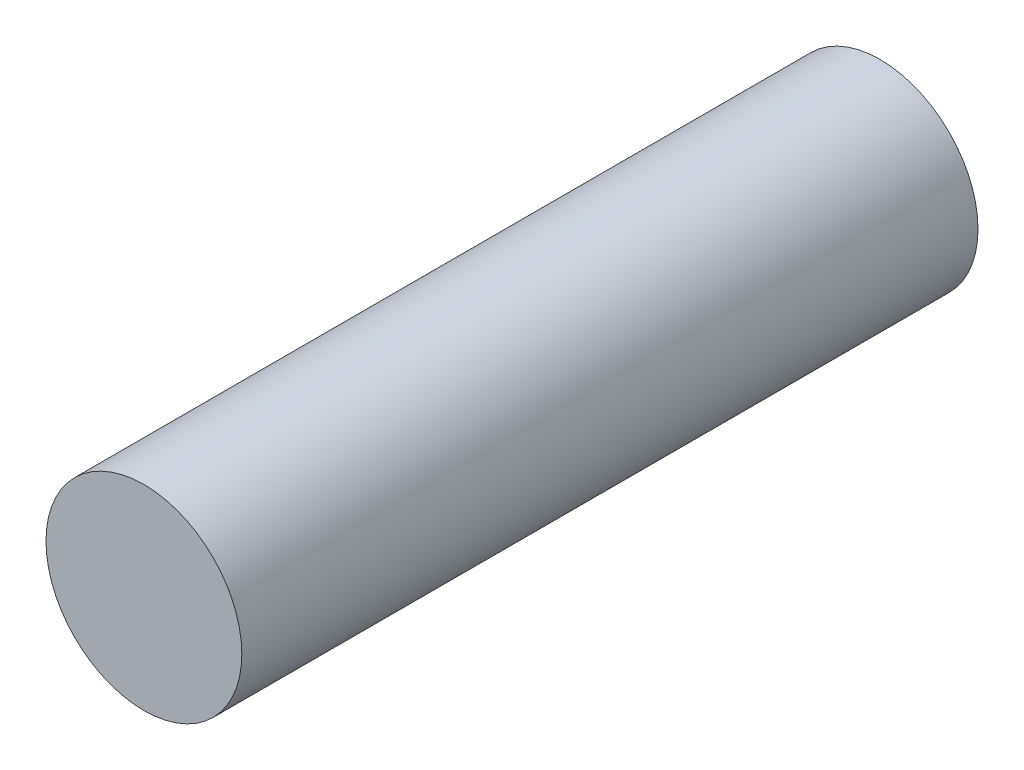
from build123d import *

# Parameters (mm, degrees)
SKETCH1_R           = 3.99
BOSS_EXTRUDE1_DEPTH = 30


with BuildPart() as part:
    # Sketch1 → Boss-Extrude1 (new body)
    with BuildSketch(Plane.XY):
        with Locations((-7.804735568, 1.216001185)):
            Circle(SKETCH1_R)
    extrude(amount=BOSS_EXTRUDE1_DEPTH)


solid = part.part
